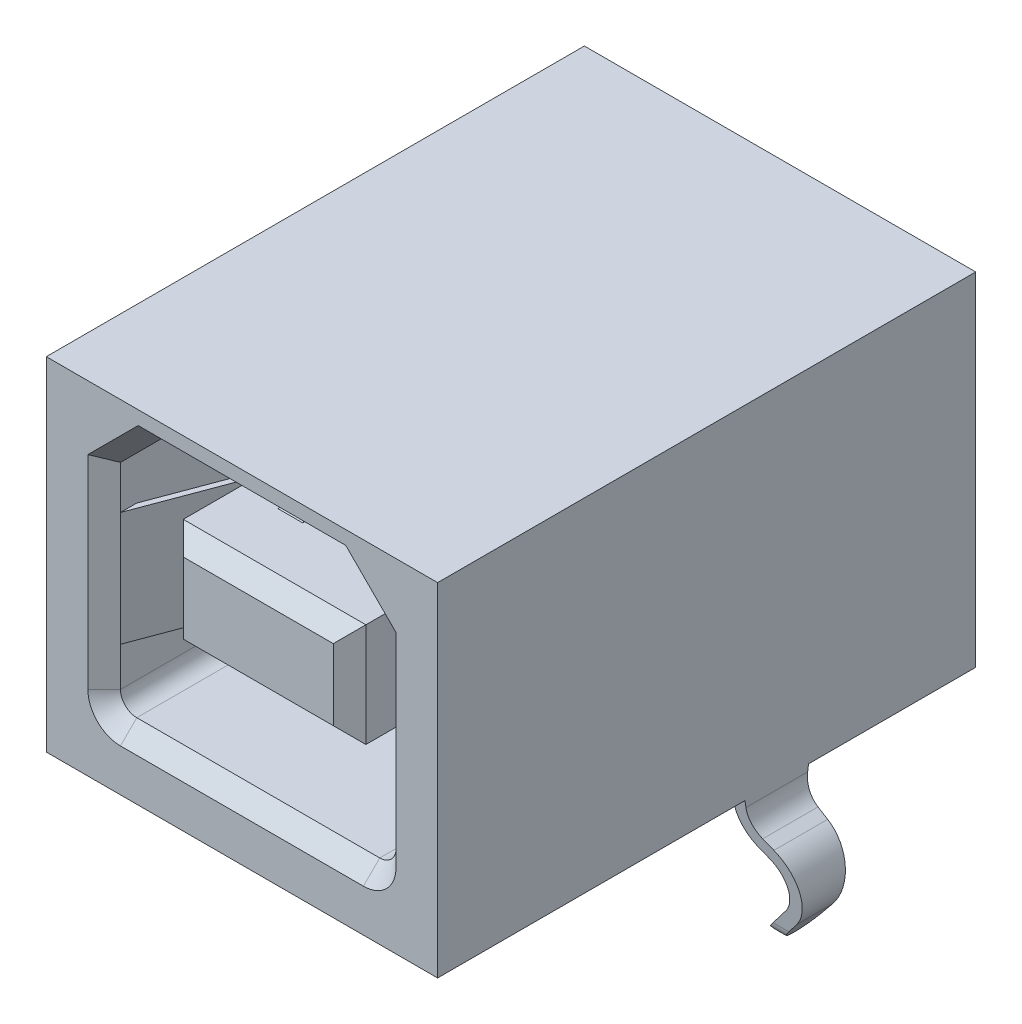
from build123d import *

# Parameters (mm, degrees)
SKETCH1_W                      = 12
SKETCH1_H                      = 10.5
BASE_DEPTH                     = 8.25
CONTACT_OPENING_DEPTH          = 9
CONTACT_OPENING_LEAD_IN_SIZE   = 0.5
SKETCH3_W                      = 5.6
SKETCH3_H                      = 3.18
CONTACT_AREA_DEPTH             = 8.5
CONTACT_AREA_LEAD_IN_SIZE      = 0.5
HOLDING_TINES_DEPTH            = 1.75
CONTACT_DEPTH                  = 0.375
CONTACT_PATTERN_COUNT          = 2
CONTACT_PATTERN_PITCH          = 2.5
TH_GROUND_LEGS_DEPTH           = 0.975
TH_GROUND_LEG_SHAPE_DEPTH      = 8.43
TH_GROUND_LEG_SHAPE_DEPTH_BACK = 8.43
TH_TAILS_DEPTH                 = 0.125
TH_TAILS_PATTERN_COUNT         = 2
TH_TAILS_PATTERN_PITCH         = 2


with BuildPart() as part:
    # Sketch1 → Base (new body, symmetric)
    with BuildSketch(Plane.XY):
        Rectangle(SKETCH1_W, SKETCH1_H)
    extrude(amount=BASE_DEPTH, both=True)

    # Sketch2 → Contact Opening (cut)
    with BuildSketch(Plane.XY.offset(8.25)):
        with BuildLine():
            Line((-2.975, 4.33), (-4.225, 3.08))
            Line((-4.225, 3.08), (-4.225, -2.95))
            ThreePointArc((-4.225, -2.95), (-4.078553391, -3.303553391), (-3.725, -3.45))
            Line((-3.725, -3.45), (3.725, -3.45))
            ThreePointArc((3.725, -3.45), (4.078553391, -3.303553391), (4.225, -2.95))
            Line((4.225, -2.95), (4.225, 3.08))
            Line((4.225, 3.08), (2.975, 4.33))
            Line((2.975, 4.33), (-2.975, 4.33))
        make_face()
    extrude(amount=-CONTACT_OPENING_DEPTH, mode=Mode.SUBTRACT)

    # Contact Opening Lead-in
    contact_opening_lead_in_edges = [part.edges().sort_by_distance(p)[0] for p in [
        (0, 4.33, 8.25),
        (-3.6, 3.705, 8.25),
        (-4.225, 0.065, 8.25),
        (-4.078553391, -3.303553391, 8.25),
        (0, -3.45, 8.25),
        (4.078553391, -3.303553391, 8.25),
        (4.225, 0.065, 8.25),
        (3.6, 3.705, 8.25),
    ]]
    chamfer(contact_opening_lead_in_edges, length=CONTACT_OPENING_LEAD_IN_SIZE)

    # Sketch3 → Contact Area (add)
    with BuildSketch(Plane.XY.offset(-0.75)):
        with Locations((0, 0.44)):
            Rectangle(SKETCH3_W, SKETCH3_H)
    extrude(amount=CONTACT_AREA_DEPTH)

    # Contact Area Lead-in
    contact_area_lead_in_edges = [part.edges().sort_by_distance(p)[0] for p in [
        (-2.8, 0.44, 7.75),
        (0, -1.15, 7.75),
        (2.8, 0.44, 7.75),
        (0, 2.03, 7.75),
    ]]
    chamfer(contact_area_lead_in_edges, length=CONTACT_AREA_LEAD_IN_SIZE)

    # Sketch7 → Holding Tines (add, symmetric)
    with BuildSketch(Plane(origin=(0, 0, 0), x_dir=(1, 0, 0), z_dir=(0, 1, 0))):
        with BuildLine():
            Line((-4.225, -7.75), (-3.215243234, -5.051316752))
            ThreePointArc((-3.215243234, -5.051316752), (-3.027350135, -3.881276433), (-3.307189725, -2.729760924))
            Line((-3.307189725, -2.729760924), (-3.695, -1.9))
            Line((-3.695, -1.9), (-3.853538933, -1.974097279))
            Line((-3.853538933, -1.974097279), (-3.465728658, -2.803858203))
            ThreePointArc((-3.465728658, -2.803858203), (-3.202213044, -3.888201975), (-3.379145712, -4.989989942))
            Line((-3.379145712, -4.989989942), (-4.388902478, -7.688673189))
            Line((-4.388902478, -7.688673189), (-4.225, -7.75))
        make_face()
        with BuildLine():
            Line((4.225, -7.75), (4.388902478, -7.688673189))
            Line((4.388902478, -7.688673189), (3.379145712, -4.989989942))
            ThreePointArc((3.379145712, -4.989989942), (3.202213044, -3.888201975), (3.465728658, -2.803858203))
            Line((3.465728658, -2.803858203), (3.853538933, -1.974097279))
            Line((3.853538933, -1.974097279), (3.695, -1.9))
            Line((3.695, -1.9), (3.307189725, -2.729760924))
            ThreePointArc((3.307189725, -2.729760924), (3.027350135, -3.881276433), (3.215243234, -5.051316752))
            Line((3.215243234, -5.051316752), (4.225, -7.75))
        make_face()
    extrude(amount=HOLDING_TINES_DEPTH, both=True)

    # Sketch8 → Contact (add, symmetric)
    with BuildSketch(Plane(origin=(-1.25, 0, 0), x_dir=(0, 0, -1), z_dir=(1, 0, 0))):
        with BuildLine():
            Line((0.75, 2.03), (-2.695251124, 2.678262825))
            ThreePointArc((-2.695251124, 2.678262825), (-3.57053143, 2.712827451), (-4.418484282, 2.493086043))
            Line((-4.418484282, 2.493086043), (-5.75, 1.93))
            Line((-5.75, 1.93), (-5.681838417, 1.768819981))
            Line((-5.681838417, 1.768819981), (-4.350322699, 2.331906024))
            ThreePointArc((-4.350322699, 2.331906024), (-3.551833763, 2.538829183), (-2.727611475, 2.506280827))
            Line((-2.727611475, 2.506280827), (0.717639649, 1.858018002))
            Line((0.717639649, 1.858018002), (0.75, 2.03))
        make_face()
        with BuildLine():
            Line((-5.681838417, -0.888819981), (-5.75, -1.05))
            Line((-5.75, -1.05), (-4.418484282, -1.613086043))
            ThreePointArc((-4.418484282, -1.613086043), (-3.57053143, -1.832827451), (-2.695251124, -1.798262825))
            Line((-2.695251124, -1.798262825), (0.75, -1.15))
            Line((0.75, -1.15), (0.717639649, -0.978018002))
            Line((0.717639649, -0.978018002), (-2.727611475, -1.626280827))
            ThreePointArc((-2.727611475, -1.626280827), (-3.551833763, -1.658829183), (-4.350322699, -1.451906024))
            Line((-4.350322699, -1.451906024), (-5.681838417, -0.888819981))
        make_face()
    contact = extrude(amount=CONTACT_DEPTH, both=True)

    # Contact Pattern: Contact ×2
    with Locations(*[(i * CONTACT_PATTERN_PITCH, 0, 0) for i in range(1, CONTACT_PATTERN_COUNT)]):
        add(contact)

    # Sketch13 → TH Ground Legs (add, symmetric)
    with BuildSketch(Plane.XY.offset(-2.15)):
        with BuildLine():
            Line((6, -5.25), (6, -5.45))
            ThreePointArc((6, -5.45), (6.112536174, -5.84514538), (6.41637299, -6.121709028))
            Line((6.41637299, -6.121709028), (6.736045017, -6.280484954))
            ThreePointArc((6.736045017, -6.280484954), (7.400291967, -7.129098698), (7.157524757, -8.179066973))
            Line((7.157524757, -8.179066973), (6.527167526, -8.97))
            Line((6.527167526, -8.97), (6.23, -8.73316364))
            Line((6.23, -8.73316364), (6.860357231, -7.942230613))
            ThreePointArc((6.860357231, -7.942230613), (7.029323209, -7.211452694), (6.567007332, -6.620817528))
            Line((6.567007332, -6.620817528), (6.247335304, -6.462041602))
            ThreePointArc((6.247335304, -6.462041602), (5.789554503, -6.045352372), (5.62, -5.45))
            Line((5.62, -5.45), (5.62, -5.25))
            Line((5.62, -5.25), (6, -5.25))
        make_face()
        with BuildLine():
            Line((-5.62, -5.25), (-6, -5.25))
            Line((-6, -5.25), (-6, -5.45))
            ThreePointArc((-6, -5.45), (-6.112536174, -5.84514538), (-6.41637299, -6.121709028))
            Line((-6.41637299, -6.121709028), (-6.736045017, -6.280484954))
            ThreePointArc((-6.736045017, -6.280484954), (-7.400291967, -7.129098698), (-7.157524757, -8.179066973))
            Line((-7.157524757, -8.179066973), (-6.527167526, -8.97))
            Line((-6.527167526, -8.97), (-6.23, -8.73316364))
            Line((-6.23, -8.73316364), (-6.860357231, -7.942230613))
            ThreePointArc((-6.860357231, -7.942230613), (-7.029323209, -7.211452694), (-6.567007332, -6.620817528))
            Line((-6.567007332, -6.620817528), (-6.247335304, -6.462041602))
            ThreePointArc((-6.247335304, -6.462041602), (-5.789554503, -6.045352372), (-5.62, -5.45))
            Line((-5.62, -5.45), (-5.62, -5.25))
        make_face()
    extrude(amount=TH_GROUND_LEGS_DEPTH, both=True)

    # Sketch14 → TH Ground Leg Shape (cut, two sides)
    with BuildSketch(Plane(origin=(0, 0, 0), x_dir=(0, 0, -1), z_dir=(1, 0, 0))) as th_ground_leg_shape_sk:
        with BuildLine():
            Line((3.125, -5.25), (3.125, -9))
            Line((3.125, -9), (1.175, -9))
            Line((1.175, -9), (1.175, -5.25))
            Line((1.175, -5.25), (1.655236252, -8.542172253))
            ThreePointArc((1.655236252, -8.542172253), (2.15, -8.97), (2.644763748, -8.542172253))
            Line((2.644763748, -8.542172253), (3.125, -5.25))
        make_face()
    extrude(amount=TH_GROUND_LEG_SHAPE_DEPTH, mode=Mode.SUBTRACT)
    extrude(th_ground_leg_shape_sk.sketch, amount=-TH_GROUND_LEG_SHAPE_DEPTH_BACK, mode=Mode.SUBTRACT)

    # Sketch15 → TH Tails (add, symmetric)
    with BuildSketch(Plane(origin=(0, 0, -7.4), x_dir=(-1, 0, 0), z_dir=(0, 0, -1))):
        Polygon((-1.58, -5.25), (-0.92, -5.25), (-0.92, -8.1), (-1.041207868, -8.4), (-1.458792132, -8.4), (-1.58, -8.1), align=None)
        Polygon((0.92, -8.1), (1.041207868, -8.4), (1.458792132, -8.4), (1.58, -8.1), (1.58, -5.25), (0.92, -5.25), align=None)
    th_tails = extrude(amount=TH_TAILS_DEPTH, both=True)

    # TH Tails Pattern: TH Tails ×2
    with Locations(*[(0, 0, i * TH_TAILS_PATTERN_PITCH) for i in range(1, TH_TAILS_PATTERN_COUNT)]):
        add(th_tails)


solid = part.part
